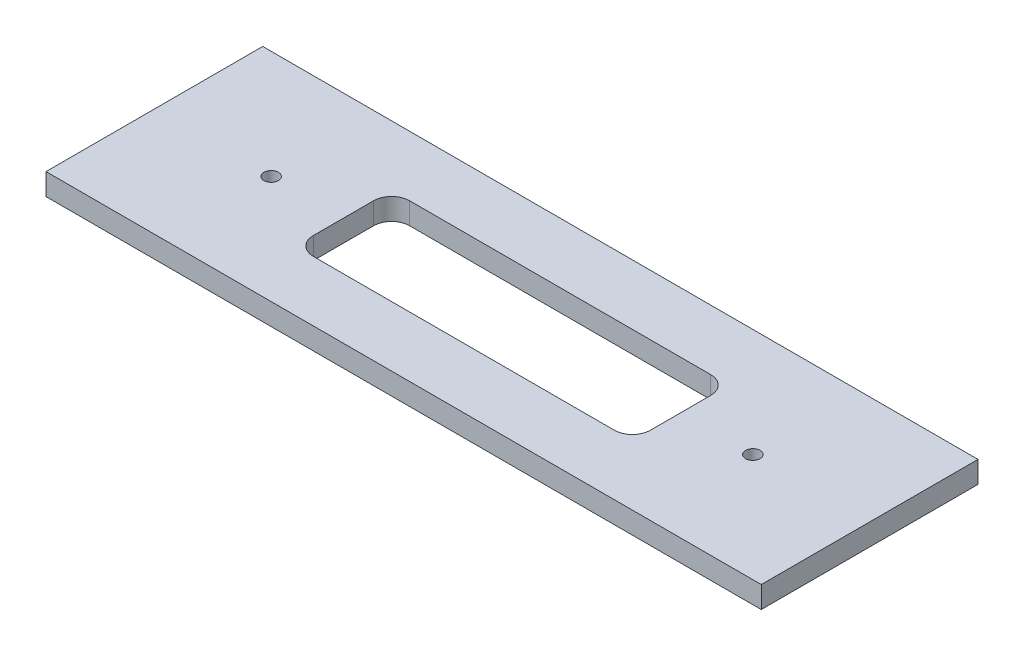
from build123d import *

# Parameters (mm, degrees)
SKETCH1_W           = 594
SKETCH1_H           = 180
BOSS_EXTRUDE1_DEPTH = 18
SKETCH2_R           = 6
CUT_EXTRUDE1_DEPTH  = 40


with BuildPart() as part:
    # Sketch1 → Boss-Extrude1 (new body)
    with BuildSketch(Plane(origin=(0, 0, 0), x_dir=(1, 0, 0), z_dir=(0, 1, 0))):
        Rectangle(SKETCH1_W, SKETCH1_H)
    extrude(amount=BOSS_EXTRUDE1_DEPTH)

    # Sketch2 → Cut-Extrude1 (cut)
    with BuildSketch(Plane(origin=(0, 18, 0), x_dir=(1, 0, 0), z_dir=(0, 1, 0))):
        with Locations((-200, 0)):
            Circle(SKETCH2_R)
        with Locations((200, 0)):
            Circle(SKETCH2_R)
        with BuildLine():
            Line((-125, -40), (125, -40))
            ThreePointArc((125, -40), (135.606601718, -35.606601718), (140, -25))
            Line((140, -25), (140, 25))
            ThreePointArc((140, 25), (135.606601718, 35.606601718), (125, 40))
            Line((125, 40), (-125, 40))
            ThreePointArc((-125, 40), (-135.606601718, 35.606601718), (-140, 25))
            Line((-140, 25), (-140, -25))
            ThreePointArc((-140, -25), (-135.606601718, -35.606601718), (-125, -40))
        make_face()
    extrude(amount=-CUT_EXTRUDE1_DEPTH, mode=Mode.SUBTRACT)


solid = part.part
